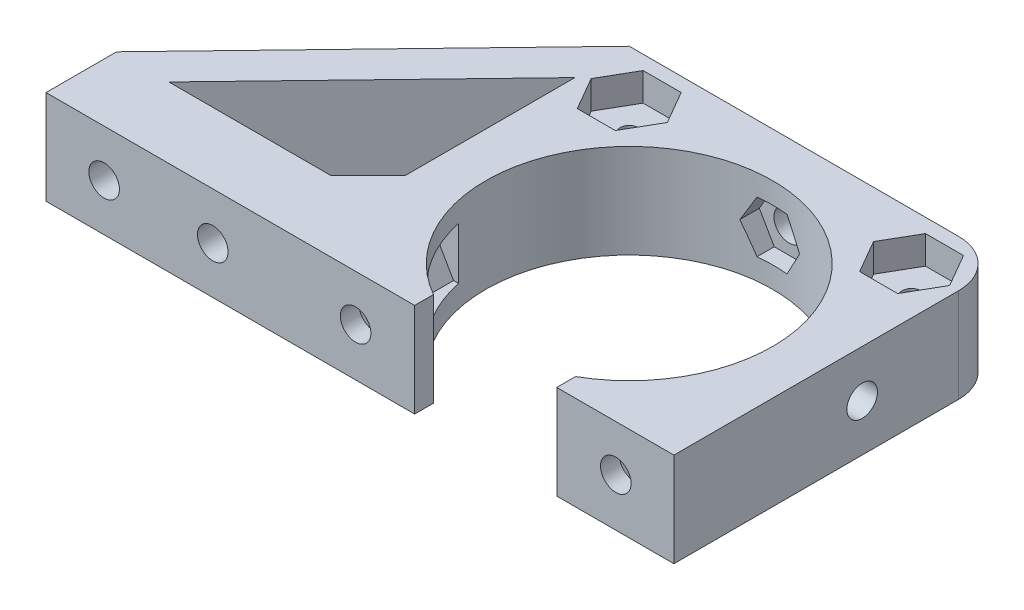
from build123d import *

# Parameters (mm, degrees)
CROQUIS1_R                              = 15.25
CROQUIS1_R_2                            = 2.125
SOPORTE_CAJA_REDUCTORA_DEPTH            = 20
CROQUIS3_R                              = 2.125
CORTAR_EXTRUIR1_DEPTH                   = 51.423828692
REDONDEO1_R                             = 5
BOSS_EXTRUDE1_DEPTH                     = 20
CUT_EXTRUDE1_REACH                      = 55.852
SKETCH2_R                               = 1.625
CUT_EXTRUDE2_DEPTH                      = 2
SKETCH4_R                               = 1.625
CUT_EXTRUDE3_DEPTH                      = 63.291652731
CUT_EXTRUDE4_START                      = -4.5
CUT_EXTRUDE4_DEPTH                      = 2
CROQUIS6_W                              = 4.75
CROQUIS6_H                              = 4.75
CORTAR_EXTRUIR17_DEPTH                  = 42.231056256
CROQUIS7_W                              = 60
CROQUIS7_H                              = 20
CORTAR_EXTRUIR18_DEPTH                  = 51.423828692
SALIENTE_EXTRUIR2_DEPTH                 = 49
SOPORTE_START                           = -15
SOPORTE_MOTOR_DEPTH                     = 15
CROQUIS12_R                             = 2.125
AGUJEROS_DE_SUJECION_A_BASE_DEPTH       = 84.087679592
TUERCA_START                            = -4
TUERCA_AGUJERO_DE_SUJECION_A_BASE_DEPTH = 10
SALIENTE_EXTRUIR4_DEPTH                 = 15
CORTAR_EXTRUIR19_DEPTH                  = 25
CROQUIS14_W                             = 50
CROQUIS14_H                             = 118
CORTAR_EXTRUIR22_DEPTH                  = 146.556045907
CROQUIS15_W                             = 10
CROQUIS15_H                             = 7
CORTAR_EXTRUIR23_DEPTH                  = 42.231056256
CORTAR_EXTRUIR24_DEPTH                  = 42.231056256
CROQUIS18_W                             = 40
CROQUIS18_H                             = 10
CORTAR_EXTRUIR25_DEPTH                  = 44.27311521
SALIENTE_EXTRUIR5_DEPTH                 = 10
CROQUIS20_R                             = 1
CORTAR_EXTRUIR26_DEPTH                  = 49.229270158
CORTAR_EXTRUIR27_REACH                  = 62.959
CORTAR_EXTRUIR27_END_RADIUS             = 15.25
CROQUIS21_R                             = 1.625
CROQUIS22_R                             = 2.125
CROQUIS22_R_2                           = 1
SALIENTE_EXTRUIR6_DEPTH                 = 10
CROQUIS23_R                             = 1.625
CORTAR_EXTRUIR28_DEPTH                  = 52.269508521
CORTAR_EXTRUIR29_START                  = -3
CORTAR_EXTRUIR29_DEPTH                  = 10
SALIENTE_EXTRUIR7_DEPTH                 = 10
CORTAR_EXTRUIR30_REACH                  = 72.235
CROQUIS27_R                             = 1.625
CORTAR_EXTRUIR31_REACH                  = 75.235
CORTAR_EXTRUIR31_START                  = -3
CORTAR_EXTRUIR32_REACH                  = 58.612
CROQUIS29_R                             = 1.625
CORTAR_EXTRUIR33_REACH                  = 61.112
CORTAR_EXTRUIR33_START                  = -2.5
CROQUIS35_W                             = 13.305418987
CROQUIS35_H                             = 6.826864192
CORTAR_EXTRUIR34_DEPTH                  = 63.931555098
CORTAR_EXTRUIR34_DEPTH_BACK             = 63.931555098
CORTAR_EXTRUIR35_START                  = -3
CORTAR_EXTRUIR35_DEPTH                  = 10
SALIENTE_EXTRUIR8_DEPTH                 = 10
SALIENTE_EXTRUIR9_DEPTH                 = 13
SALIENTE_EXTRUIR10_DEPTH                = 3
CROQUIS40_W                             = 106.583537839
CROQUIS40_H                             = 47.391515964
CORTAR_EXTRUIR36_DEPTH                  = 80.887064817
CORTAR_EXTRUIR36_DEPTH_BACK             = 80.887064817
CORTAR_EXTRUIR37_DEPTH                  = 67.2524009
CORTAR_EXTRUIR37_DEPTH_BACK             = 67.2524009
CORTAR_EXTRUIR38_DEPTH                  = 79.704784639
CORTAR_EXTRUIR38_DEPTH_BACK             = 79.704784639
SALIENTE_EXTRUIR11_DEPTH                = 10
CORTAR_EXTRUIR39_DEPTH                  = 63.9908649
CROQUIS45_W                             = 31.470301378
CROQUIS45_H                             = 10
CROQUIS45_R                             = 1.625
SALIENTE_EXTRUIR12_DEPTH                = 2.5
SALIENTE_EXTRUIR13_DEPTH                = 10
CORTAR_EXTRUIR40_START                  = -2
CROQUIS47_R                             = 1.625
CORTAR_EXTRUIR40_DEPTH                  = 10
CORTAR_EXTRUIR41_START                  = -12
CROQUIS48_R                             = 1.625
CORTAR_EXTRUIR41_DEPTH                  = 12
CORTAR_EXTRUIR42_DEPTH                  = 3


with BuildPart() as part:
    # Croquis1 → Soporte caja reductora (new body)
    with BuildSketch(Plane(origin=(0, 0, 0), x_dir=(1, 0, 0), z_dir=(0, 1, 0))):
        Polygon((-30, -15.25), (-20, -15.25), (-20, -20), (20, -20), (20, -15.25), (30, -15.25), (30, -7.25), (20, -4.25), (20, 20), (-20, 20), (-20, -4.25), (-30, -7.25), align=None)
        with Locations(Location((0, 0, 0), (0, 0, 270))):
            Circle(CROQUIS1_R, mode=Mode.SUBTRACT)
        with Locations(Location((-15, 15, 0), (0, 0, 270))):
            Circle(CROQUIS1_R_2, mode=Mode.SUBTRACT)
        with Locations(Location((15, 15, 0), (0, 0, 270))):
            Circle(CROQUIS1_R_2, mode=Mode.SUBTRACT)
    extrude(amount=-SOPORTE_CAJA_REDUCTORA_DEPTH)

    # Croquis3 → Cortar-Extruir1 (cut, through all)
    with BuildSketch(Plane.XY.offset(15.25)):
        with Locations((-23.5, -10)):
            Circle(CROQUIS3_R)
        with Locations((23.5, -10)):
            Circle(CROQUIS3_R)
    extrude(amount=-CORTAR_EXTRUIR1_DEPTH, mode=Mode.SUBTRACT)

    # Redondeo1
    redondeo1_edges = [part.edges().sort_by_distance(p)[0] for p in [
        (-20, -10, -20),
        (20, -10, -20),
    ]]
    fillet(redondeo1_edges, radius=REDONDEO1_R)

    # Sketch1 → Boss-Extrude1 (add)
    with BuildSketch(Plane(origin=(0, 0, 0), x_dir=(1, 0, 0), z_dir=(0, 1, 0))):
        with BuildLine():
            Line((25.5, 15), (20, 15))
            ThreePointArc((20, 15), (18.535533906, 18.535533906), (15, 20))
            Line((15, 20), (30, 20))
            Line((30, 20), (30, 8))
            Line((30, 8), (25.5, 8))
            Line((25.5, 8), (25.5, 15))
        make_face()
    extrude(amount=-BOSS_EXTRUDE1_DEPTH)

    # Sketch2 → Cut-Extrude1 (cut, up to next)
    with BuildSketch(Plane(origin=(0, 0, -20), x_dir=(-1, 0, 0), z_dir=(0, 0, -1)), mode=Mode.PRIVATE) as cut_extrude1_sk1:
        with Locations((-22.75, -10)):
            Circle(SKETCH2_R)
    cut_extrude1_tool1 = extrude(cut_extrude1_sk1.sketch, amount=-CUT_EXTRUDE1_REACH, mode=Mode.PRIVATE) & part.part
    add(cut_extrude1_tool1.solids().sort_by_distance((22.75, -10, -20))[0], mode=Mode.SUBTRACT)

    # Sketch3 → Cut-Extrude2 (cut)
    with BuildSketch(Plane.XY.offset(-15)):
        Polygon((20, -11.58771324), (22.75, -13.175426481), (25.5, -11.58771324), (25.5, -8.41228676), (22.75, -6.824573519), (20, -8.41228676), align=None)
    extrude(amount=-CUT_EXTRUDE2_DEPTH, mode=Mode.SUBTRACT)

    # Sketch4 → Cut-Extrude3 (cut, through all)
    with BuildSketch(Plane.ZY.offset(-25.5)):
        with Locations((-12.25, -10)):
            Circle(SKETCH4_R)
    extrude(amount=-CUT_EXTRUDE3_DEPTH, mode=Mode.SUBTRACT)

    # Sketch5 → Cut-Extrude4 (cut)
    with BuildSketch(Plane(origin=(30, 0, 0), x_dir=(0, 0, -1), z_dir=(1, 0, 0)).offset(CUT_EXTRUDE4_START)):
        Polygon((15, -11.58771324), (15, -8.41228676), (12.25, -6.824573519), (9.5, -8.41228676), (9.5, -11.58771324), (12.25, -13.175426481), align=None)
    extrude(amount=CUT_EXTRUDE4_DEPTH, mode=Mode.SUBTRACT)

    # Croquis6 → Cortar-Extruir17 (cut, through all)
    with BuildSketch(Plane(origin=(0, 0, 0), x_dir=(1, 0, 0), z_dir=(0, 1, 0))):
        Polygon((0, -15.25), (-15.25, -15.25), (-15.25, -20), (15.25, -20), (15.25, -15.25), align=None)
        with Locations((-17.625, -17.625)):
            Rectangle(CROQUIS6_W, CROQUIS6_H)
        with BuildLine():
            ThreePointArc((0, -15.25), (-10.783378413, -10.783378413), (-15.25, 0))
            Line((-15.25, 0), (-15.25, -15.25))
            Line((-15.25, -15.25), (0, -15.25))
        make_face()
        with BuildLine():
            Line((15.25, -15.25), (15.25, 0))
            ThreePointArc((15.25, 0), (10.783378413, -10.783378413), (0, -15.25))
            Line((0, -15.25), (15.25, -15.25))
        make_face()
        with Locations((17.625, -17.625)):
            Rectangle(CROQUIS6_W, CROQUIS6_H)
    extrude(amount=-CORTAR_EXTRUIR17_DEPTH, mode=Mode.SUBTRACT)


with BuildPart() as body_2:
    # Simetría1: mirrored copy
    add(part.part.mirror(Plane.ZX))

    # Croquis8 → Saliente-Extruir2 (add)
    with BuildSketch(Plane(origin=(0, 20, 0), x_dir=(1, 0, 0), z_dir=(0, 1, 0))):
        with BuildLine():
            Line((-12.664515522, 20), (-11.040489496, 13.939052358))
            Line((-11.040489496, 13.939052358), (-10.315162126, 11.232093763))
            ThreePointArc((-10.315162126, 11.232093763), (0, 15.25), (10.315162126, 11.232093763))
            Line((10.315162126, 11.232093763), (10.817418481, 13.87928066))
            Line((10.817418481, 13.87928066), (11.978715476, 20))
            Line((11.978715476, 20), (-12.664515522, 20))
        make_face()
    extrude(amount=SALIENTE_EXTRUIR2_DEPTH)

    # Croquis9 → Soporte motor (add)
    with BuildSketch(Plane(origin=(0, 69, 0), x_dir=(1, 0, 0), z_dir=(0, 1, 0)).offset(SOPORTE_START)):
        with BuildLine():
            Line((-20, 15), (-20, -4.25))
            Line((-20, -4.25), (-30, -7.25))
            Line((-30, -7.25), (-30, -15.25))
            Line((-30, -15.25), (0, -15.25))
            Line((0, -15.25), (0, -14.75))
            ThreePointArc((0, -14.75), (-10.429825023, 10.429825023), (14.75, 0))
            Line((14.75, 0), (20, 0))
            Line((20, 0), (20, 13.936837101))
            Line((20, 13.936837101), (12.664515522, 20))
            Line((12.664515522, 20), (-15, 20))
            ThreePointArc((-15, 20), (-18.535533906, 18.535533906), (-20, 15))
        make_face()
    extrude(amount=-SOPORTE_MOTOR_DEPTH)

    # Croquis12 → Agujeros de sujecion a base (cut, through all)
    with BuildSketch(Plane.XY.offset(15.25)):
        with Locations((-23.5, 46.5)):
            Circle(CROQUIS12_R)
    extrude(amount=-AGUJEROS_DE_SUJECION_A_BASE_DEPTH, mode=Mode.SUBTRACT)

    # Croquis13 → Tuerca Agujero de sujecion a base (cut)
    with BuildSketch(Plane.XY.offset(15.25).offset(TUERCA_START)):
        Polygon((-20, 44.479274058), (-20, 48.520725942), (-23.5, 50.541451884), (-27, 48.520725942), (-27, 44.479274058), (-23.5, 42.458548116), align=None)
    extrude(amount=-TUERCA_AGUJERO_DE_SUJECION_A_BASE_DEPTH, mode=Mode.SUBTRACT)

    # Croquis10 → Saliente-Extruir4 (add)
    with BuildSketch(Plane(origin=(0, 69, 0), x_dir=(1, 0, 0), z_dir=(0, 1, 0))):
        with BuildLine():
            ThreePointArc((10.315162126, 11.232093763), (0, 15.25), (-10.315162126, 11.232093763))
            Line((-10.315162126, 11.232093763), (-10.16850369, 10.684757026))
            ThreePointArc((-10.16850369, 10.684757026), (0, 14.75), (10.16850369, 10.684757026))
            Line((10.16850369, 10.684757026), (10.315162126, 11.232093763))
        make_face()
    extrude(amount=-SALIENTE_EXTRUIR4_DEPTH)

    # Croquis11 → Cortar-Extruir19 (cut)
    with BuildSketch(Plane.XZ):
        with BuildLine():
            Line((15.25, 4.25), (20, 4.25))
            Line((20, 4.25), (21.972856468, 4.84185694))
            ThreePointArc((21.972856468, 4.84185694), (19.948931102, 10.40625523), (16.543503257, 15.25))
            Line((16.543503257, 15.25), (15.25, 15.25))
            Line((15.25, 15.25), (15.25, 4.25))
        make_face()
        with BuildLine():
            Line((21.972856468, 4.84185694), (30, 7.25))
            Line((30, 7.25), (30, 15.25))
            Line((30, 15.25), (16.543503257, 15.25))
            ThreePointArc((16.543503257, 15.25), (19.948931102, 10.40625523), (21.972856468, 4.84185694))
        make_face()
        with BuildLine():
            ThreePointArc((20, -15), (18.535533906, -18.535533906), (15, -20))
            Line((15, -20), (30, -20))
            Line((30, -20), (30, -8))
            Line((30, -8), (25.5, -8))
            Line((25.5, -8), (25.5, -15))
            Line((25.5, -15), (20, -15))
        make_face()
    extrude(amount=-CORTAR_EXTRUIR19_DEPTH, mode=Mode.SUBTRACT)

    # Simetría2: body 2 across face


with BuildPart() as part_1:
    add(part.part)

    # Croquis7 → Cortar-Extruir18 (cut, through all)
    with BuildSketch(Plane(origin=(0, 0, -20), x_dir=(-1, 0, 0), z_dir=(0, 0, -1))):
        with Locations((0, -10)):
            Rectangle(CROQUIS7_W, CROQUIS7_H)
    extrude(amount=-CORTAR_EXTRUIR18_DEPTH, mode=Mode.SUBTRACT)


with BuildPart() as body_2_1:
    add(body_2.part)
    add(body_2.part.mirror(Plane(origin=(-0.229209569, 69, -16.663998028), x_dir=(0, 0, 1), z_dir=(0, 1, 0))))

    # Croquis14 → Cortar-Extruir22 (cut, through all)
    with BuildSketch(Plane.XY.offset(15.25)):
        with Locations((-5, 79)):
            Rectangle(CROQUIS14_W, CROQUIS14_H)
    extrude(amount=-CORTAR_EXTRUIR22_DEPTH, mode=Mode.SUBTRACT)

    # Croquis15 → Cortar-Extruir23 (cut, through all)
    with BuildSketch(Plane.XZ):
        with Locations((-25, 7.75)):
            Rectangle(CROQUIS15_W, CROQUIS15_H)
    extrude(amount=-CORTAR_EXTRUIR23_DEPTH, mode=Mode.SUBTRACT)

    # Croquis16 → Cortar-Extruir24 (cut, through all)
    with BuildSketch(Plane.XZ):
        Polygon((-30, 15.25), (-15.25, 15.25), (-15.25, 12.75), (-20, 12.75), (-20, 11.25), (-30, 11.25), (-30, 12.75), align=None)
    extrude(amount=-CORTAR_EXTRUIR24_DEPTH, mode=Mode.SUBTRACT)

    # Croquis18 → Cortar-Extruir25 (cut, through all)
    with BuildSketch(Plane(origin=(0, 0, -20), x_dir=(-1, 0, 0), z_dir=(0, 0, -1))):
        with Locations((0, 5)):
            Rectangle(CROQUIS18_W, CROQUIS18_H)
    extrude(amount=-CORTAR_EXTRUIR25_DEPTH, mode=Mode.SUBTRACT)

    # Croquis19 → Saliente-Extruir5 (add)
    with BuildSketch(Plane(origin=(0, 20, 0), x_dir=(1, 0, 0), z_dir=(0, 1, 0))):
        Polygon((-20, -12.75), (-34, -12.75), (-34, -7.75), (-24, -7.75), (-20, -3.75), align=None)
    extrude(amount=-SALIENTE_EXTRUIR5_DEPTH)

    # Croquis20 → Cortar-Extruir26 (cut, through all)
    with BuildSketch(Plane(origin=(0, 0, 7.75), x_dir=(-1, 0, 0), z_dir=(0, 0, -1))):
        with Locations((29, 15)):
            Circle(CROQUIS20_R)
    extrude(amount=-CORTAR_EXTRUIR26_DEPTH, mode=Mode.SUBTRACT)

    # Cortar-Extruir27: up to this cylinder (the profile starts outside it)
    cortar_extruir27_end = Plane(origin=(0, 15, 0), z_dir=(0, -1, 0)) * Cylinder(CORTAR_EXTRUIR27_END_RADIUS, 157.418, mode=Mode.PRIVATE)
    # Croquis21 → Cortar-Extruir27 (cut, up to the surface)
    with BuildSketch(Plane(origin=(20, 0, 0), x_dir=(0, 0, -1), z_dir=(1, 0, 0)), mode=Mode.PRIVATE) as cortar_extruir27_sk1:
        with Locations((4.75, 15)):
            Circle(CROQUIS21_R)
    cortar_extruir27_tool1 = extrude(cortar_extruir27_sk1.sketch, amount=-CORTAR_EXTRUIR27_REACH, mode=Mode.PRIVATE) - cortar_extruir27_end
    add(cortar_extruir27_tool1.solids().sort_by_distance((20, 15, -4.75))[0], mode=Mode.SUBTRACT)

    # Croquis22 → Saliente-Extruir6 (add)
    with BuildSketch(Plane.XZ.offset(-10)):
        with Locations((-15, -15)):
            Circle(CROQUIS22_R)
        with Locations(Location((-15, -15, 0), (0, 0, 270))):
            Circle(CROQUIS22_R_2, mode=Mode.SUBTRACT)
        with Locations((15, -15)):
            Circle(CROQUIS22_R)
        with Locations(Location((15, -15, 0), (0, 0, 270))):
            Circle(CROQUIS22_R_2, mode=Mode.SUBTRACT)
    extrude(amount=-SALIENTE_EXTRUIR6_DEPTH)

    # Croquis23 → Cortar-Extruir28 (cut, through all)
    with BuildSketch(Plane(origin=(0, 0, -20), x_dir=(-1, 0, 0), z_dir=(0, 0, -1))):
        with Locations((0, 15)):
            Circle(CROQUIS23_R)
    extrude(amount=-CORTAR_EXTRUIR28_DEPTH, mode=Mode.SUBTRACT)

    # Croquis24 → Cortar-Extruir29 (cut)
    with BuildSketch(Plane(origin=(0, 0, -20), x_dir=(-1, 0, 0), z_dir=(0, 0, -1)).offset(CORTAR_EXTRUIR29_START)):
        Polygon((1.58771324, 12.25), (3.175426481, 15), (1.58771324, 17.75), (-1.58771324, 17.75), (-3.175426481, 15), (-1.58771324, 12.25), align=None)
    extrude(amount=-CORTAR_EXTRUIR29_DEPTH, mode=Mode.SUBTRACT)

    # Croquis26 → Saliente-Extruir7 (add)
    with BuildSketch(Plane.XZ.offset(-10)):
        Polygon((-34, 7.75), (-34, 12.75), (-58.825, 12.75), (-39.160527763, -4.104491148), (-20, -4.104491148), (-20, -0.104491148), (-35.732113118, -0.104491148), (-29, 7.75), align=None)
        Polygon((-34.268209086, 7.75), (-39.594516123, 1.535690951), (-46.844874897, 7.75), align=None, mode=Mode.SUBTRACT)
    extrude(amount=-SALIENTE_EXTRUIR7_DEPTH)

    # Croquis27 → Cortar-Extruir30 (cut, up to next)
    with BuildSketch(Plane.XY.offset(12.75), mode=Mode.PRIVATE) as cortar_extruir30_sk1:
        with Locations((-40.544874897, 15)):
            Circle(CROQUIS27_R)
    cortar_extruir30_tool1 = extrude(cortar_extruir30_sk1.sketch, amount=-CORTAR_EXTRUIR30_REACH, mode=Mode.PRIVATE) & body_2_1.part
    # Croquis27 → Cortar-Extruir30 (cut, up to next)
    with BuildSketch(Plane.XY.offset(12.75), mode=Mode.PRIVATE) as cortar_extruir30_sk2:
        with Locations((-29, 15)):
            Circle(CROQUIS27_R)
    cortar_extruir30_tool2 = extrude(cortar_extruir30_sk2.sketch, amount=-CORTAR_EXTRUIR30_REACH, mode=Mode.PRIVATE) & body_2_1.part
    add(cortar_extruir30_tool1.solids().sort_by_distance((-40.544875, 15, 12.75))[0], mode=Mode.SUBTRACT)
    add(cortar_extruir30_tool2.solids().sort_by_distance((-29, 15, 12.75))[0], mode=Mode.SUBTRACT)

    # Croquis28 → Cortar-Extruir31 (cut, up to next)
    with BuildSketch(Plane.XY.offset(12.75).offset(CORTAR_EXTRUIR31_START), mode=Mode.PRIVATE) as cortar_extruir31_sk1:
        Polygon((-38.957161657, 12.25), (-37.369448416, 15), (-38.957161657, 17.75), (-42.132588137, 17.75), (-43.720301378, 15), (-42.132588137, 12.25), align=None)
    cortar_extruir31_tool1 = extrude(cortar_extruir31_sk1.sketch, amount=-CORTAR_EXTRUIR31_REACH, mode=Mode.PRIVATE) & body_2_1.part
    # Croquis28 → Cortar-Extruir31 (cut, up to next)
    with BuildSketch(Plane.XY.offset(12.75).offset(CORTAR_EXTRUIR31_START), mode=Mode.PRIVATE) as cortar_extruir31_sk2:
        Polygon((-27.41228676, 12.25), (-25.824573519, 15), (-27.41228676, 17.75), (-30.58771324, 17.75), (-32.175426481, 15), (-30.58771324, 12.25), align=None)
    cortar_extruir31_tool2 = extrude(cortar_extruir31_sk2.sketch, amount=-CORTAR_EXTRUIR31_REACH, mode=Mode.PRIVATE) & body_2_1.part
    add(cortar_extruir31_tool1.solids().sort_by_distance((-40.544875, 15, 9.75))[0], mode=Mode.SUBTRACT)
    add(cortar_extruir31_tool2.solids().sort_by_distance((-29, 15, 9.75))[0], mode=Mode.SUBTRACT)

    # Croquis29 → Cortar-Extruir32 (cut, up to next)
    with BuildSketch(Plane(origin=(-18.612848159, 0, -21.715982563), x_dir=(-0.7592713073348843, 0, 0.6507742172658468), z_dir=(-0.6507742172658468, 0, -0.7592713073348843)), mode=Mode.PRIVATE) as cortar_extruir32_sk1:
        with Locations((33.812368097, 15)):
            Circle(CROQUIS29_R)
    cortar_extruir32_tool1 = extrude(cortar_extruir32_sk1.sketch, amount=-CORTAR_EXTRUIR32_REACH, mode=Mode.PRIVATE) & body_2_1.part
    add(cortar_extruir32_tool1.solids().sort_by_distance((-44.285609, 15, 0.288235))[0], mode=Mode.SUBTRACT)

    # Croquis31 → Cortar-Extruir33 (cut, up to next)
    with BuildSketch(Plane(origin=(-18.612848159, 0, -21.715982563), x_dir=(-0.7592713073348843, 0, 0.6507742172658468), z_dir=(-0.6507742172658468, 0, -0.7592713073348843)).offset(CORTAR_EXTRUIR33_START), mode=Mode.PRIVATE) as cortar_extruir33_sk1:
        Polygon((36.562368097, 16.58771324), (33.812368097, 18.175426481), (31.062368097, 16.58771324), (31.062368097, 13.41228676), (33.812368097, 11.824573519), (36.562368097, 13.41228676), align=None)
    cortar_extruir33_tool1 = extrude(cortar_extruir33_sk1.sketch, amount=-CORTAR_EXTRUIR33_REACH, mode=Mode.PRIVATE) & body_2_1.part
    add(cortar_extruir33_tool1.solids().sort_by_distance((-42.658674, 15, 2.186413))[0], mode=Mode.SUBTRACT)

    # Croquis35 → Cortar-Extruir34 (cut, two sides)
    with BuildSketch(Plane(origin=(0, 20, 0), x_dir=(1, 0, 0), z_dir=(0, 1, 0))) as cortar_extruir34_sk:
        with Locations((17.04227466, -3.413432096)):
            Rectangle(CROQUIS35_W, CROQUIS35_H)
    extrude(amount=CORTAR_EXTRUIR34_DEPTH, mode=Mode.SUBTRACT)
    extrude(cortar_extruir34_sk.sketch, amount=-CORTAR_EXTRUIR34_DEPTH_BACK, mode=Mode.SUBTRACT)

    # Croquis36 → Cortar-Extruir35 (cut)
    with BuildSketch(Plane(origin=(20, 0, 0), x_dir=(0, 0, -1), z_dir=(1, 0, 0)).offset(CORTAR_EXTRUIR35_START)):
        Polygon((7.5, 16.58771324), (4.75, 18.175426481), (2, 16.58771324), (2, 13.41228676), (4.75, 11.824573519), (7.5, 13.41228676), align=None)
    extrude(amount=-CORTAR_EXTRUIR35_DEPTH, mode=Mode.SUBTRACT)

    # Croquis37 → Saliente-Extruir8 (add)
    with BuildSketch(Plane.XZ.offset(-10)):
        Polygon((-39.160527763, -4.104491148), (-20.614919368, -20), (-15, -20), (-19.558128305, -15.637570403), (-33.014002756, -4.104491148), align=None)
    extrude(amount=-SALIENTE_EXTRUIR8_DEPTH)

    # Croquis38 → Saliente-Extruir9 (add)
    with BuildSketch(Plane.XZ.offset(-10)):
        Polygon((-58.825, 12.75), (-38.825, 12.75), (-38.825, 9.75), (-55.324839942, 9.75), align=None)
    extrude(amount=SALIENTE_EXTRUIR9_DEPTH)

    # Croquis39 → Saliente-Extruir10 (add)
    with BuildSketch(Plane.XZ.offset(-10)):
        Polygon((-38.825, 9.75), (-38.825, 7.75), (-38.825, 5.75), (-50.657959865, 5.75), (-52.991399903, 7.75), (-55.324839942, 9.75), align=None)
    extrude(amount=SALIENTE_EXTRUIR10_DEPTH)

    # Simetría3: body 2 across face


with BuildPart() as body_2_2:
    add(body_2_1.part)
    add(body_2_1.part.mirror(Plane(origin=(-18.003999227, 20, -4.220503046), x_dir=(0, 0, 1), z_dir=(0, 1, 0))))

    # Croquis40 → Cortar-Extruir36 (cut, two sides)
    with BuildSketch(Plane(origin=(0, 0, -20), x_dir=(-1, 0, 0), z_dir=(0, 0, -1))) as cortar_extruir36_sk:
        with Locations((22.395502026, -3.695757982)):
            Rectangle(CROQUIS40_W, CROQUIS40_H)
    extrude(amount=CORTAR_EXTRUIR36_DEPTH, mode=Mode.SUBTRACT)
    extrude(cortar_extruir36_sk.sketch, amount=-CORTAR_EXTRUIR36_DEPTH_BACK, mode=Mode.SUBTRACT)

    # Croquis41 → Cortar-Extruir37 (cut, two sides)
    with BuildSketch(Plane.XZ.offset(-20)) as cortar_extruir37_sk:
        Polygon((-19.992980133, -22.302484261), (-20, 3.75), (-24, 7.75), (-56.035110209, 7.75), align=None)
    extrude(amount=CORTAR_EXTRUIR37_DEPTH, mode=Mode.SUBTRACT)
    extrude(cortar_extruir37_sk.sketch, amount=-CORTAR_EXTRUIR37_DEPTH_BACK, mode=Mode.SUBTRACT)

    # Croquis42 → Cortar-Extruir38 (cut, two sides)
    with BuildSketch(Plane(origin=(0, 0, 9.75), x_dir=(-1, 0, 0), z_dir=(0, 0, -1))) as cortar_extruir38_sk:
        Polygon((46.720301378, 20), (46.720301378, 30), (38.825, 30), (33.492952769, 43.760628779), (49.525340398, 48.951442806), (67.200390695, 42.512205152), (65.906601328, 20), (51.713995885, 13.864168239), align=None)
    extrude(amount=CORTAR_EXTRUIR38_DEPTH, mode=Mode.SUBTRACT)
    extrude(cortar_extruir38_sk.sketch, amount=-CORTAR_EXTRUIR38_DEPTH_BACK, mode=Mode.SUBTRACT)

    # Croquis43 → Saliente-Extruir11 (add)
    with BuildSketch(Plane.XZ.offset(-20)):
        Polygon((-19.993600539, -20), (-46.720301378, 7.75), (-43.839252857, 10.524807997), (-17.112552018, -17.225192003), align=None)
    extrude(amount=-SALIENTE_EXTRUIR11_DEPTH)

    # Croquis44 → Cortar-Extruir39 (cut, through all)
    with BuildSketch(Plane(origin=(0, 0, 9.75), x_dir=(-1, 0, 0), z_dir=(0, 0, -1))):
        Polygon((38.957161657, 27.75), (37.369448416, 25), (38.957161657, 22.25), (42.132588137, 22.25), (43.720301378, 25), (42.132588137, 27.75), align=None)
    extrude(amount=CORTAR_EXTRUIR39_DEPTH, mode=Mode.SUBTRACT)

    # Croquis45 → Saliente-Extruir12 (add)
    with BuildSketch(Plane.XY.offset(12.75)):
        with Locations((-30.985150689, 25)):
            Rectangle(CROQUIS45_W, CROQUIS45_H)
        with Locations((-40.544874897, 25)):
            Circle(CROQUIS45_R, mode=Mode.SUBTRACT)
        with Locations((-29, 25)):
            Circle(CROQUIS45_R, mode=Mode.SUBTRACT)
    extrude(amount=SALIENTE_EXTRUIR12_DEPTH)

    # Croquis46 → Saliente-Extruir13 (add)
    with BuildSketch(Plane.XZ.offset(-20)):
        with BuildLine():
            Line((15.25, 0), (20, 0))
            Line((20, 0), (20, 15.25))
            Line((20, 15.25), (7.549834435, 15.25))
            Line((7.549834435, 15.25), (7.549834435, 13.25))
            ThreePointArc((7.549834435, 13.25), (13.185171124, 7.662490615), (15.25, 0))
        make_face()
        with BuildLine():
            Line((-15.25, 0), (-15.25, 15.25))
            Line((-15.25, 15.25), (-7.549834435, 15.25))
            Line((-7.549834435, 15.25), (-7.549834435, 13.25))
            ThreePointArc((-7.549834435, 13.25), (-13.185171124, 7.662490615), (-15.25, 0))
        make_face()
    extrude(amount=-SALIENTE_EXTRUIR13_DEPTH)

    # Croquis47 → Cortar-Extruir40 (cut)
    with BuildSketch(Plane.XY.offset(15.25).offset(CORTAR_EXTRUIR40_START)):
        Polygon((15.41228676, 22.352505966), (17, 25.102505966), (15.41228676, 27.852505966), (12.236860279, 27.852505966), (10.649147039, 25.102505966), (12.236860279, 22.352505966), align=None)
        with Locations((13.824573519, 25.102505966)):
            Circle(CROQUIS47_R, mode=Mode.SUBTRACT)
        Polygon((-12.236860279, 22.352505966), (-15.41228676, 22.352505966), (-17, 25.102505966), (-15.41228676, 27.852505966), (-12.236860279, 27.852505966), (-10.649147039, 25.102505966), align=None)
        with Locations(Location((-13.824573519, 25.102505966, 0), (0, 0, 131.421584744))):
            Circle(CROQUIS47_R, mode=Mode.SUBTRACT)
    extrude(amount=-CORTAR_EXTRUIR40_DEPTH, mode=Mode.SUBTRACT)

    # Croquis48 → Cortar-Extruir41 (cut)
    with BuildSketch(Plane.XY.offset(15.25).offset(CORTAR_EXTRUIR41_START)):
        with Locations((13.824573519, 25.102505966)):
            Circle(CROQUIS48_R)
        with Locations((-13.824573519, 25.102505966)):
            Circle(CROQUIS48_R)
    extrude(amount=CORTAR_EXTRUIR41_DEPTH, mode=Mode.SUBTRACT)

    # Croquis49 → Cortar-Extruir42 (cut)
    with BuildSketch(Plane(origin=(0, 30, 0), x_dir=(1, 0, 0), z_dir=(0, 1, 0))):
        Polygon((-12.979274058, 11.5), (-10.958548116, 15), (-12.979274058, 18.5), (-17.020725942, 18.5), (-19.041451884, 15), (-17.020725942, 11.5), align=None)
        Polygon((17.020725942, 11.5), (19.041451884, 15), (17.020725942, 18.5), (12.979274058, 18.5), (10.958548116, 15), (12.979274058, 11.5), align=None)
    extrude(amount=-CORTAR_EXTRUIR42_DEPTH, mode=Mode.SUBTRACT)


solid = body_2_2.part
